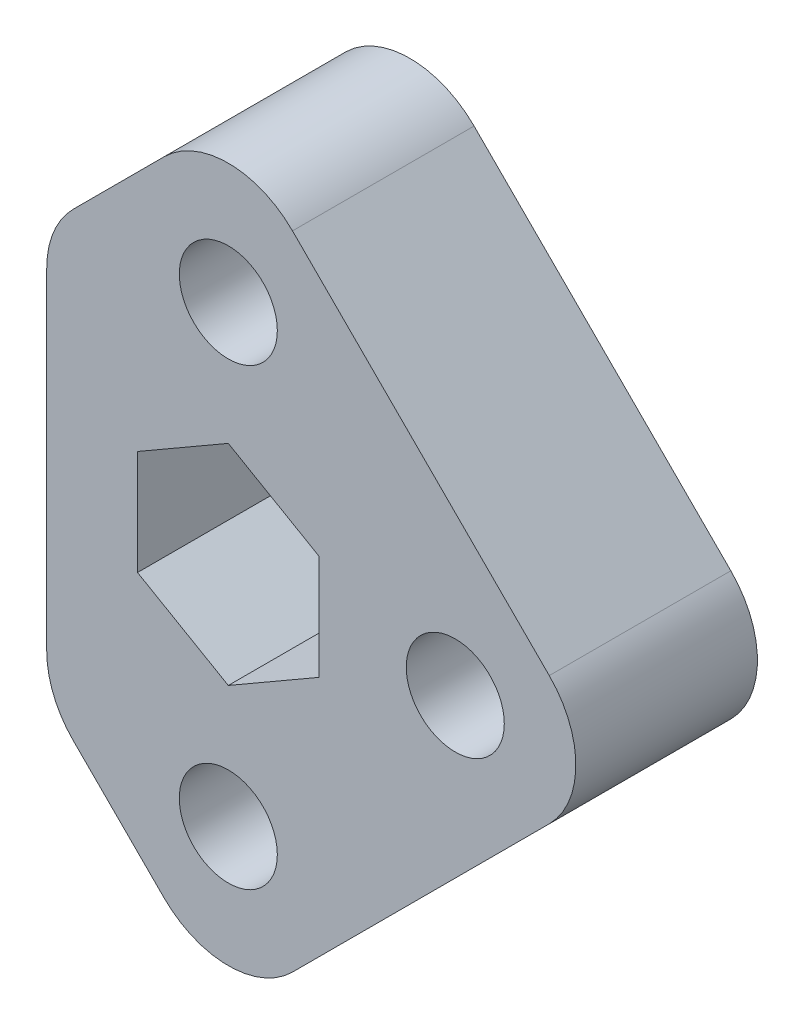
from build123d import *

# Parameters (mm, degrees)
SKETCH2_R           = 3.429
BOSS_EXTRUDE1_DEPTH = 12.7


with BuildPart() as part:
    # Sketch2 → Boss-Extrude1 (new body)
    with BuildSketch(Plane.XY):
        with BuildLine():
            Line((-4.490128061, 22.450640303), (-10.840128061, 16.100640303))
            ThreePointArc((-10.840128061, 16.100640303), (-12.216635031, 14.040552038), (-12.7, 11.610512242))
            Line((-12.7, 11.610512242), (-12.7, -11.610512242))
            ThreePointArc((-12.7, -11.610512242), (-12.216635031, -14.040552038), (-10.840128061, -16.100640303))
            Line((-10.840128061, -16.100640303), (-4.490128061, -22.450640303))
            ThreePointArc((-4.490128061, -22.450640303), (0, -24.310512242), (4.490128061, -22.450640303))
            Line((4.490128061, -22.450640303), (22.450640303, -4.490128061))
            ThreePointArc((22.450640303, -4.490128061), (24.310512242, 0), (22.450640303, 4.490128061))
            Line((22.450640303, 4.490128061), (4.490128061, 22.450640303))
            ThreePointArc((4.490128061, 22.450640303), (0, 24.310512242), (-4.490128061, 22.450640303))
        make_face()
        with Locations((0, 15.875)):
            Circle(SKETCH2_R, mode=Mode.SUBTRACT)
        with Locations((15.875, 0)):
            Circle(SKETCH2_R, mode=Mode.SUBTRACT)
        with Locations((0, -15.875)):
            Circle(SKETCH2_R, mode=Mode.SUBTRACT)
        Polygon((6.35, 3.666174209), (0, 7.332348419), (-6.35, 3.666174209), (-6.35, -3.666174209), (0, -7.332348419), (6.35, -3.666174209), align=None, mode=Mode.SUBTRACT)
    extrude(amount=BOSS_EXTRUDE1_DEPTH)


solid = part.part
